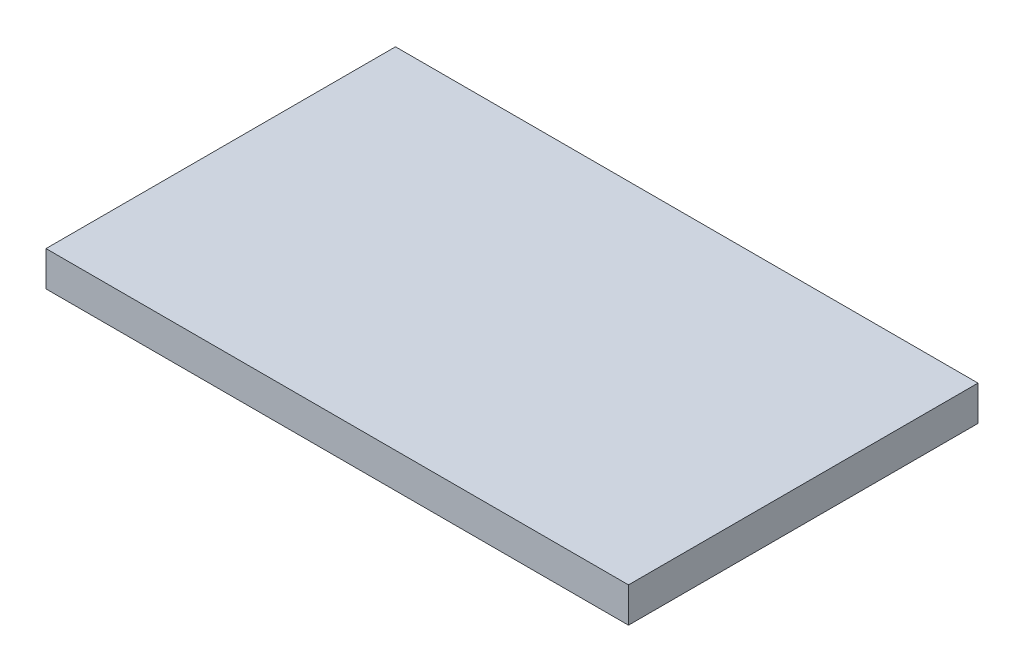
from build123d import *

# Parameters (mm, degrees)
SKETCH1_W           = 25
SKETCH1_H           = 15
BOSS_EXTRUDE1_DEPTH = 1.5


with BuildPart() as part:
    # Sketch1 → Boss-Extrude1 (new body)
    with BuildSketch(Plane(origin=(0, 0, 0), x_dir=(1, 0, 0), z_dir=(0, 1, 0))):
        with Locations((12.5, 7.5)):
            Rectangle(SKETCH1_W, SKETCH1_H)
    extrude(amount=BOSS_EXTRUDE1_DEPTH)


solid = part.part
